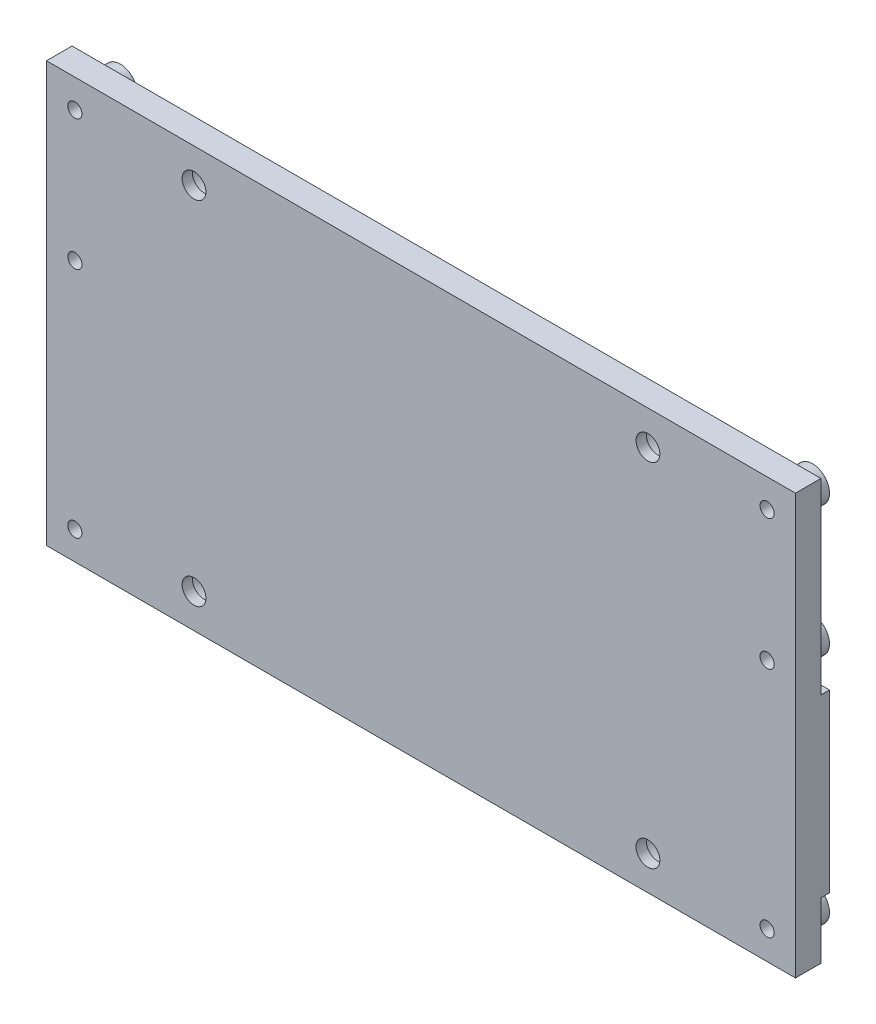
from build123d import *

# Parameters (mm, degrees)
ESQUISSE2_W                = 132
ESQUISSE2_H                = 74
BOSS_EXTRU_1_DEPTH         = 4.5
BOSS_EXTRU_PWRSTAGES_DEPTH = 1.5
ENL_V_MAT_SELFS_DEPTH      = 1.25
ESQUISSE6_W                = 127.502
ESQUISSE6_H                = 30.958
BOSS_EXTRU_ASICS_DEPTH     = 1.5
ESQUISSE7_R                = 3
BOSS_EXTRU_FIXS_DEPTH      = 3.5
TROU_TARAUD_M31_D          = 2.5
TROU_TARAUD_M31_DEPTH      = 8
ESQUISSE15_R               = 2.1
ENL_V_MAT_EXTRU_1_DEPTH    = 5.5
ENL_V_START                = 3.5
ESQUISSE16_R               = 3.5
ENL_V_MAT_EXTRU_3_DEPTH    = 6.2


with BuildPart() as part:
    # Esquisse2 → Boss.-Extru.1 (new body)
    with BuildSketch(Plane.XY):
        with Locations((147, -83)):
            Rectangle(ESQUISSE2_W, ESQUISSE2_H)
    extrude(amount=BOSS_EXTRU_1_DEPTH)

    # Esquisse4 → Boss.-Extru. PWRstages (add)
    with BuildSketch(Plane(origin=(0, 0, 0), x_dir=(-1, 0, 0), z_dir=(0, 0, -1))):
        with BuildLine():
            Line((-190.85, -58), (-185.85, -58))
            ThreePointArc((-185.85, -58), (-184.435786438, -58.585786438), (-183.85, -60))
            Line((-183.85, -60), (-183.85, -64))
            ThreePointArc((-183.85, -64), (-184.435786438, -65.414213562), (-185.85, -66))
            Line((-185.85, -66), (-190.85, -66))
            ThreePointArc((-190.85, -66), (-192.264213562, -65.414213562), (-192.85, -64))
            Line((-192.85, -64), (-192.85, -60))
            ThreePointArc((-192.85, -60), (-192.264213562, -58.585786438), (-190.85, -58))
        make_face()
        with BuildLine():
            Line((-125.911169345, -57.999392956), (-120.911169345, -57.999392956))
            ThreePointArc((-120.911169345, -57.999392956), (-119.496955783, -58.585179394), (-118.911169345, -59.999392956))
            Line((-118.911169345, -59.999392956), (-118.911169345, -63.999392956))
            ThreePointArc((-118.911169345, -63.999392956), (-119.496955783, -65.413606518), (-120.911169345, -65.999392956))
            Line((-120.911169345, -65.999392956), (-125.911169345, -65.999392956))
            ThreePointArc((-125.911169345, -65.999392956), (-127.325382908, -65.413606518), (-127.911169345, -63.999392956))
            Line((-127.911169345, -63.999392956), (-127.911169345, -59.999392956))
            ThreePointArc((-127.911169345, -59.999392956), (-127.325382908, -58.585179394), (-125.911169345, -57.999392956))
        make_face()
        with BuildLine():
            Line((-158.396550345, -57.998313843), (-153.396550345, -57.998313843))
            ThreePointArc((-153.396550345, -57.998313843), (-151.982336782, -58.584100281), (-151.396550345, -59.998313843))
            Line((-151.396550345, -59.998313843), (-151.396550345, -63.998313843))
            ThreePointArc((-151.396550345, -63.998313843), (-151.982336782, -65.412527406), (-153.396550345, -65.998313843))
            Line((-153.396550345, -65.998313843), (-158.396550345, -65.998313843))
            ThreePointArc((-158.396550345, -65.998313843), (-159.810763907, -65.412527406), (-160.396550345, -63.998313843))
            Line((-160.396550345, -63.998313843), (-160.396550345, -59.998313843))
            ThreePointArc((-160.396550345, -59.998313843), (-159.810763907, -58.584100281), (-158.396550345, -57.998313843))
        make_face()
        with BuildLine():
            Line((-93.473877357, -58.003087947), (-88.473877357, -58.003087947))
            ThreePointArc((-88.473877357, -58.003087947), (-87.059663795, -58.588874385), (-86.473877357, -60.003087947))
            Line((-86.473877357, -60.003087947), (-86.473877357, -64.003087947))
            ThreePointArc((-86.473877357, -64.003087947), (-87.059663795, -65.417301509), (-88.473877357, -66.003087947))
            Line((-88.473877357, -66.003087947), (-93.473877357, -66.003087947))
            ThreePointArc((-93.473877357, -66.003087947), (-94.888090919, -65.417301509), (-95.473877357, -64.003087947))
            Line((-95.473877357, -64.003087947), (-95.473877357, -60.003087947))
            ThreePointArc((-95.473877357, -60.003087947), (-94.888090919, -58.588874385), (-93.473877357, -58.003087947))
        make_face()
    extrude(amount=BOSS_EXTRU_PWRSTAGES_DEPTH)

    # Esquisse3 → Enlèv. mat.-SELFs (cut, symmetric)
    with BuildSketch(Plane(origin=(0, 0, 0), x_dir=(-1, 0, 0), z_dir=(0, 0, -1))):
        with BuildLine():
            Line((-203.755, -59.925), (-193.755, -59.925))
            ThreePointArc((-193.755, -59.925), (-192.340786438, -60.510786438), (-191.755, -61.925))
            Line((-191.755, -61.925), (-191.755, -68.925))
            ThreePointArc((-191.755, -68.925), (-192.340786438, -70.339213562), (-193.755, -70.925))
            Line((-193.755, -70.925), (-203.755, -70.925))
            ThreePointArc((-203.755, -70.925), (-205.169213562, -70.339213562), (-205.755, -68.925))
            Line((-205.755, -68.925), (-205.755, -61.925))
            ThreePointArc((-205.755, -61.925), (-205.169213562, -60.510786438), (-203.755, -59.925))
        make_face()
        with BuildLine():
            Line((-171.301526488, -59.932281425), (-161.301526488, -59.932281425))
            ThreePointArc((-161.301526488, -59.932281425), (-159.887312925, -60.518067862), (-159.301526488, -61.932281425))
            Line((-159.301526488, -61.932281425), (-159.301526488, -68.932281425))
            ThreePointArc((-159.301526488, -68.932281425), (-159.887312925, -70.346494987), (-161.301526488, -70.932281425))
            Line((-161.301526488, -70.932281425), (-171.301526488, -70.932281425))
            ThreePointArc((-171.301526488, -70.932281425), (-172.71574005, -70.346494987), (-173.301526488, -68.932281425))
            Line((-173.301526488, -68.932281425), (-173.301526488, -61.932281425))
            ThreePointArc((-173.301526488, -61.932281425), (-172.71574005, -60.518067862), (-171.301526488, -59.932281425))
        make_face()
        with BuildLine():
            Line((-138.836257744, -59.927884864), (-128.836257744, -59.927884864))
            ThreePointArc((-128.836257744, -59.927884864), (-127.422044181, -60.513671302), (-126.836257744, -61.927884864))
            Line((-126.836257744, -61.927884864), (-126.836257744, -68.927884864))
            ThreePointArc((-126.836257744, -68.927884864), (-127.422044181, -70.342098426), (-128.836257744, -70.927884864))
            Line((-128.836257744, -70.927884864), (-138.836257744, -70.927884864))
            ThreePointArc((-138.836257744, -70.927884864), (-140.250471306, -70.342098426), (-140.836257744, -68.927884864))
            Line((-140.836257744, -68.927884864), (-140.836257744, -61.927884864))
            ThreePointArc((-140.836257744, -61.927884864), (-140.250471306, -60.513671302), (-138.836257744, -59.927884864))
        make_face()
        with BuildLine():
            Line((-106.349673037, -59.931395797), (-96.349673037, -59.931395797))
            ThreePointArc((-96.349673037, -59.931395797), (-94.935459474, -60.517182235), (-94.349673037, -61.931395797))
            Line((-94.349673037, -61.931395797), (-94.349673037, -68.931395797))
            ThreePointArc((-94.349673037, -68.931395797), (-94.935459474, -70.34560936), (-96.349673037, -70.931395797))
            Line((-96.349673037, -70.931395797), (-106.349673037, -70.931395797))
            ThreePointArc((-106.349673037, -70.931395797), (-107.763886599, -70.34560936), (-108.349673037, -68.931395797))
            Line((-108.349673037, -68.931395797), (-108.349673037, -61.931395797))
            ThreePointArc((-108.349673037, -61.931395797), (-107.763886599, -60.517182235), (-106.349673037, -59.931395797))
        make_face()
    extrude(amount=ENL_V_MAT_SELFS_DEPTH, both=True, mode=Mode.SUBTRACT)

    # Esquisse6 → Boss.-Extru. ASICs (add)
    with BuildSketch(Plane(origin=(0, 0, 0), x_dir=(-1, 0, 0), z_dir=(0, 0, -1))):
        with Locations((-149.249, -94.521)):
            Rectangle(ESQUISSE6_W, ESQUISSE6_H)
    extrude(amount=BOSS_EXTRU_ASICS_DEPTH)

    # Esquisse7 → Boss.-Extru. FIXs (add)
    with BuildSketch(Plane(origin=(0, 0, 0), x_dir=(-1, 0, 0), z_dir=(0, 0, -1))):
        with Locations((-208, -51)):
            Circle(ESQUISSE7_R)
        with Locations((-86, -51)):
            Circle(ESQUISSE7_R)
        with Locations((-86, -74)):
            Circle(ESQUISSE7_R)
        with Locations((-86, -115)):
            Circle(ESQUISSE7_R)
        with Locations((-208, -115)):
            Circle(ESQUISSE7_R)
        with Locations((-208, -74)):
            Circle(ESQUISSE7_R)
    extrude(amount=BOSS_EXTRU_FIXS_DEPTH)

    # Trou taraudé M31
    with Locations(Plane(origin=(0, 0, -3.5), x_dir=(-1, 0, 0), z_dir=(0, 0, -1))):
        with Locations((-208, -115), (-208, -74), (-208, -51), (-86, -51), (-86, -74), (-86, -115)):
            Hole(TROU_TARAUD_M31_D / 2, depth=TROU_TARAUD_M31_DEPTH)

    # Esquisse15 → Enlèv. mat.-Extru.1 (cut, through all)
    with BuildSketch(Plane(origin=(0, 0, 0), x_dir=(-1, 0, 0), z_dir=(0, 0, -1))):
        with Locations((-187, -52)):
            Circle(ESQUISSE15_R)
        with Locations((-107, -52)):
            Circle(ESQUISSE15_R)
        with Locations((-187, -114)):
            Circle(ESQUISSE15_R)
        with Locations((-107, -114)):
            Circle(ESQUISSE15_R)
    extrude(amount=-ENL_V_MAT_EXTRU_1_DEPTH, mode=Mode.SUBTRACT)

    # Esquisse16 → Enlèv. mat.-Extru.3 (cut)
    with BuildSketch(Plane(origin=(0, 0, 0), x_dir=(-1, 0, 0), z_dir=(0, 0, -1)).offset(ENL_V_START)):
        with Locations((-187, -52)):
            Circle(ESQUISSE16_R)
        with Locations((-107, -52)):
            Circle(ESQUISSE16_R)
        with Locations((-107, -114)):
            Circle(ESQUISSE16_R)
        with Locations((-187, -114)):
            Circle(ESQUISSE16_R)
    extrude(amount=-ENL_V_MAT_EXTRU_3_DEPTH, mode=Mode.SUBTRACT)


solid = part.part
